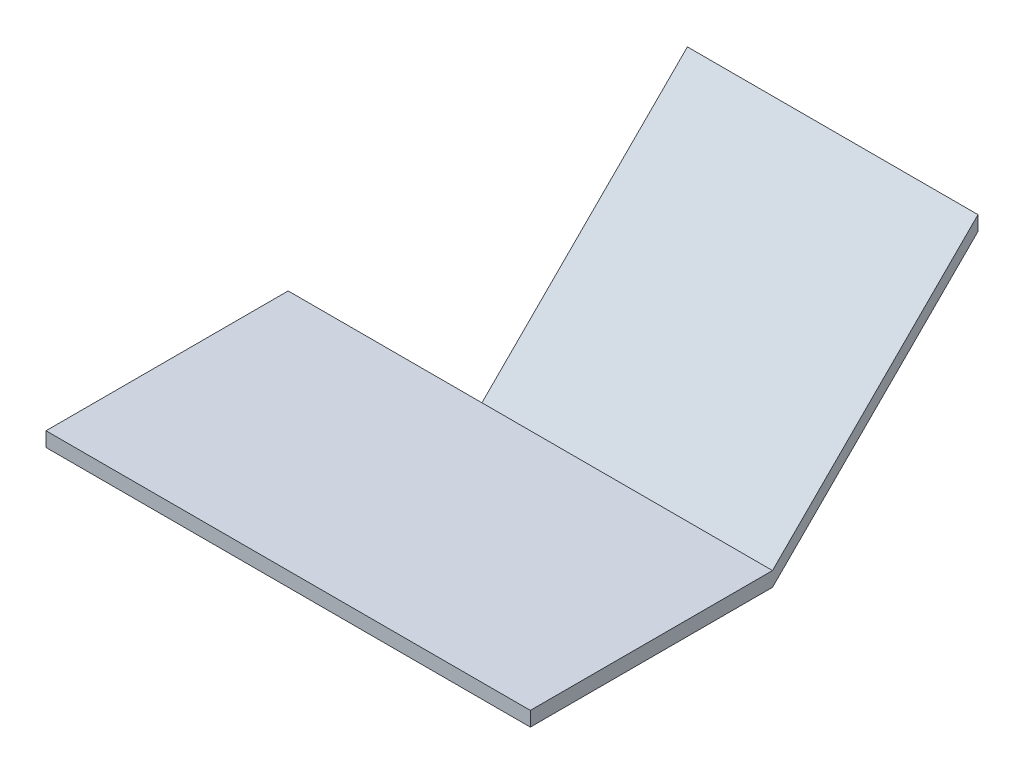
from build123d import *

# Parameters (mm, degrees)
SKETCH2_W           = 100
SKETCH2_H           = 50
BOSS_EXTRUDE1_DEPTH = 3
BOSS_EXTRUDE2_DEPTH = 60


with BuildPart() as part:
    # Sketch2 → Boss-Extrude1 (new body)
    with BuildSketch(Plane(origin=(0, 0, 0), x_dir=(1, 0, 0), z_dir=(0, 1, 0))):
        Rectangle(SKETCH2_W, SKETCH2_H)
    extrude(amount=-BOSS_EXTRUDE1_DEPTH)

    # Sketch3 → Boss-Extrude2 (add)
    with BuildSketch(Plane(origin=(50, 0, 0), x_dir=(0, 0, -1), z_dir=(1, 0, 0))):
        Polygon((25, 0), (67.426406871, 42.426406871), (67.426406871, 39.426406871), (25, -3), align=None)
    extrude(amount=-BOSS_EXTRUDE2_DEPTH)


solid = part.part
